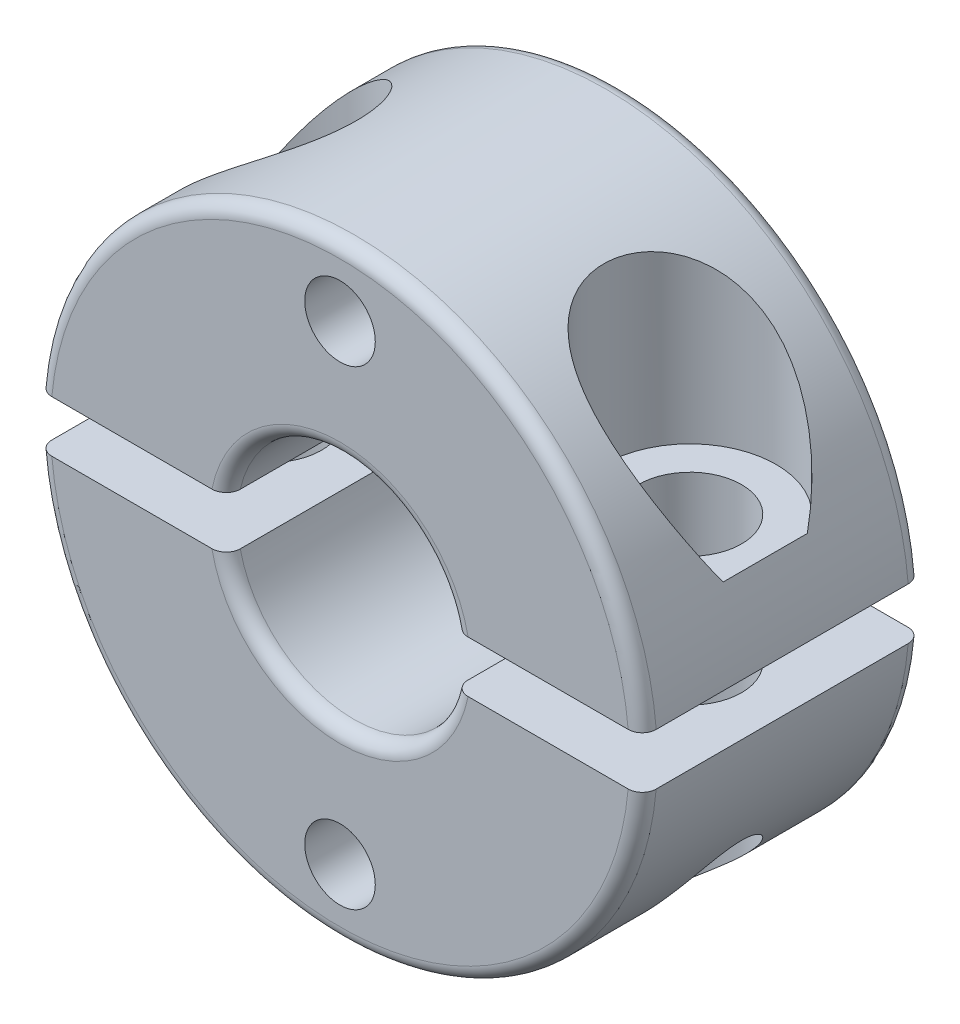
from build123d import *

# Parameters (mm, degrees)
EXTRUDE1_DEPTH                = 4.7625
EXTRUDE1_2_DEPTH              = 4.7625
FILLET1_R                     = 0.47625
FILLET2_R                     = 0.47625
SKETCH8_R                     = 1.7526
CUT_EXTRUDE3_DEPTH            = 14.82474385
SKETCH10_W                    = 1.2
SKETCH10_H                    = 9.553399824
M2_CLEARANCE_HOLE1_AT_2_COUNT = 2
M2_CLEARANCE_HOLE1_AT_2_PITCH = 16


with BuildPart() as part:
    # Sketch1 → Extrude1 (new body, symmetric)
    with BuildSketch(Plane.XY):
        with BuildLine():
            Line((-10.281405941, 0.87709375), (-3.870617924, 0.87709375))
            ThreePointArc((-3.870617924, 0.87709375), (0, 3.96875), (3.870617924, 0.87709375))
            Line((3.870617924, 0.87709375), (10.281405941, 0.87709375))
            ThreePointArc((10.281405941, 0.87709375), (0, 10.31875), (-10.281405941, 0.87709375))
        make_face()
    extrude(amount=EXTRUDE1_DEPTH, both=True)

    # Fillet1
    fillet1_edges = [part.edges().sort_by_distance(p)[0] for p in [
        (0, 3.96875, 4.7625),
        (0, 10.31875, 4.7625),
        (0, 3.96875, -4.7625),
        (0, 10.31875, -4.7625),
    ]]
    fillet(fillet1_edges, radius=FILLET1_R)


with BuildPart() as body_2:
    # Sketch1 → Extrude1 2 (new body, symmetric)
    with BuildSketch(Plane.XY):
        with BuildLine():
            Line((-10.281405941, -0.87709375), (-3.870617924, -0.87709375))
            ThreePointArc((-3.870617924, -0.87709375), (0, -3.96875), (3.870617924, -0.87709375))
            Line((3.870617924, -0.87709375), (10.281405941, -0.87709375))
            ThreePointArc((10.281405941, -0.87709375), (0, -10.31875), (-10.281405941, -0.87709375))
        make_face()
    extrude(amount=EXTRUDE1_2_DEPTH, both=True)

    # Fillet2
    fillet2_edges = [body_2.edges().sort_by_distance(p)[0] for p in [
        (0, -3.96875, 4.7625),
        (0, -10.31875, 4.7625),
        (0, -3.96875, -4.7625),
        (0, -10.31875, -4.7625),
    ]]
    fillet(fillet2_edges, radius=FILLET2_R)


with BuildPart() as cut_revolve1_tool:
    # Sketch2 → Cut-Revolve1 (revolve)
    with BuildSketch(Plane(origin=(0, 0, 0), x_dir=(1, 0, 0), z_dir=(0, 1, 0))):
        with BuildLine():
            Line((-7.33425, 4.7625), (-6.95325, 4.7625))
            ThreePointArc((-6.95325, 4.7625), (-7.14375, 4.572), (-7.33425, 4.7625))
        make_face()
    revolve(axis=Axis((0, 0, -4.7625), (0, 0, 1)))


with BuildPart() as part_1:
    add(part.part)

    # Cut-Revolve1: cut by cut_revolve1_tool
    add(cut_revolve1_tool.part, mode=Mode.SUBTRACT)


with BuildPart() as body_2_1:
    add(body_2.part)

    # Cut-Revolve1: cut by cut_revolve1_tool
    add(cut_revolve1_tool.part, mode=Mode.SUBTRACT)


with BuildPart() as cut_revolve2_tool:
    # Sketch3 → Cut-Revolve2 (revolve)
    with BuildSketch(Plane.XY):
        Polygon((-7.14375, 10.31875), (-4.21005, 10.31875), (-4.21005, 3.50599375), (-5.39115, 3.50599375), (-5.39115, -10.31875), (-7.14375, -10.31875), align=None)
    cut_revolve2 = revolve(axis=Axis((-7.14375, -10.31875, 0), (0, 1, 0)))


with BuildPart() as part_2:
    add(part_1.part)

    # Cut-Revolve2: cut by cut_revolve2_tool
    add(cut_revolve2_tool.part, mode=Mode.SUBTRACT)

    # Mirror1: Cut-Revolve2 across plane
    add(cut_revolve2.mirror(Plane(origin=(0, 0, 0), x_dir=(0, 0, 1), z_dir=(1, 0, 0))), mode=Mode.SUBTRACT)

    # Sketch10 → M2 Clearance Hole1 (revolve, cut)
    with BuildSketch(Plane(origin=(0, 8, -4.7625), x_dir=(0, 1, 0), z_dir=(1, 0, 0))):
        with Locations((0.6, 4.776699912)):
            Rectangle(SKETCH10_W, SKETCH10_H)
    m2_clearance_hole1 = revolve(axis=Axis((0, 8, -11.1125), (0, 0, 1)), mode=Mode.SUBTRACT)


with BuildPart() as body_2_2:
    add(body_2_1.part)

    # Cut-Revolve2: cut by cut_revolve2_tool
    add(cut_revolve2_tool.part, mode=Mode.SUBTRACT)

    # Sketch8 → Cut-Extrude3 (cut, through all)
    with BuildSketch(Plane(origin=(0, 3.50599375, 0), x_dir=(1, 0, 0), z_dir=(0, 1, 0))):
        with Locations((7.14375, 0)):
            Circle(SKETCH8_R)
    extrude(amount=-CUT_EXTRUDE3_DEPTH, mode=Mode.SUBTRACT)

    # M2 Clearance Hole1 at 2: M2 Clearance Hole1 ×2
    with Locations(*[(0, -i * M2_CLEARANCE_HOLE1_AT_2_PITCH, 0) for i in range(1, M2_CLEARANCE_HOLE1_AT_2_COUNT)]):
        add(m2_clearance_hole1, mode=Mode.SUBTRACT)


solid = Compound([part_2.part, body_2_2.part])
